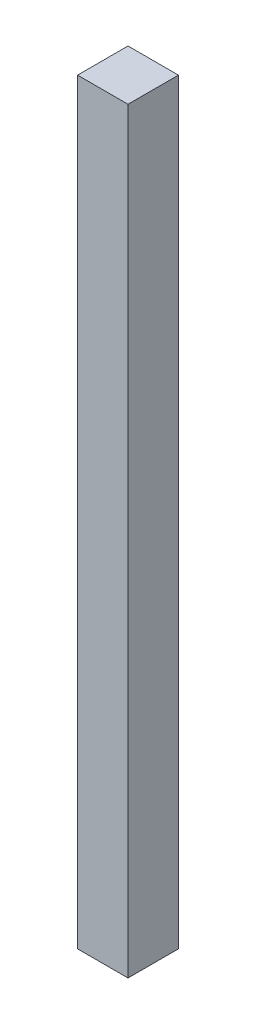
from build123d import *

# Parameters (mm, degrees)
SKETCH1_W           = 25.4
SKETCH1_H           = 25.4
BOSS_EXTRUDE1_DEPTH = 381


with BuildPart() as part:
    # Sketch1 → Boss-Extrude1 (new body)
    with BuildSketch(Plane(origin=(0, 0, 0), x_dir=(1, 0, 0), z_dir=(0, 1, 0))):
        with Locations((12.7, 12.7)):
            Rectangle(SKETCH1_W, SKETCH1_H)
    extrude(amount=BOSS_EXTRUDE1_DEPTH)


solid = part.part
